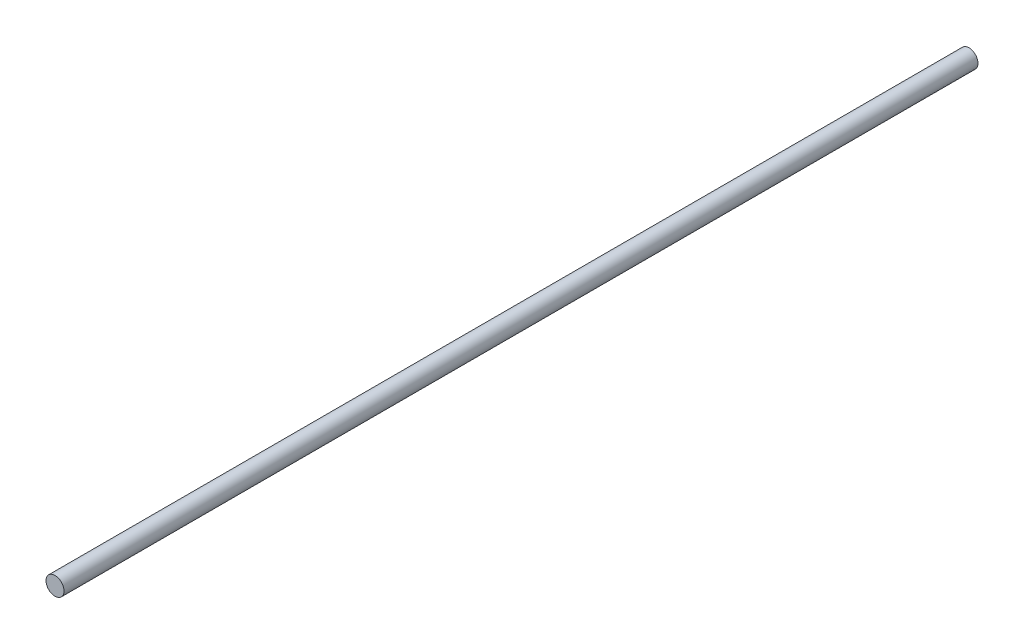
from build123d import *

# Parameters (mm, degrees)
SKETCH1_R           = 2.38125
BOSS_EXTRUDE1_DEPTH = 241.3


with BuildPart() as part:
    # Sketch1 → Boss-Extrude1 (new body)
    with BuildSketch(Plane.XY):
        Circle(SKETCH1_R)
    extrude(amount=BOSS_EXTRUDE1_DEPTH)


solid = part.part
